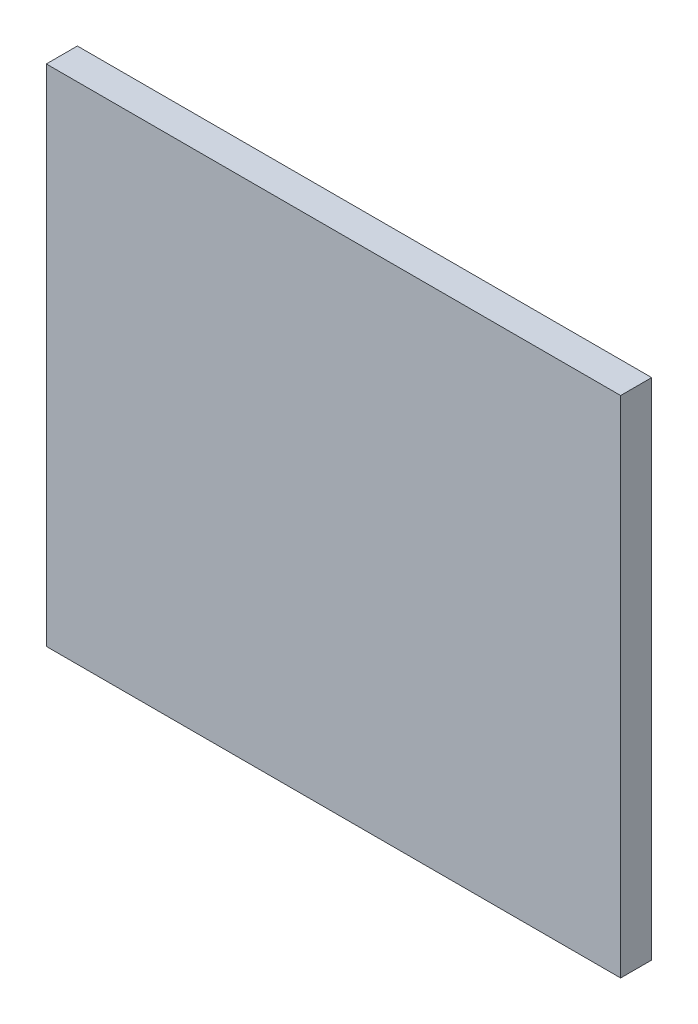
from build123d import *

# Parameters (mm, degrees)
SKETCH1_W           = 74
SKETCH1_H           = 65
BOSS_EXTRUDE1_DEPTH = 4


with BuildPart() as part:
    # Sketch1 → Boss-Extrude1 (new body)
    with BuildSketch(Plane.XY):
        Rectangle(SKETCH1_W, SKETCH1_H)
    extrude(amount=BOSS_EXTRUDE1_DEPTH)


solid = part.part
